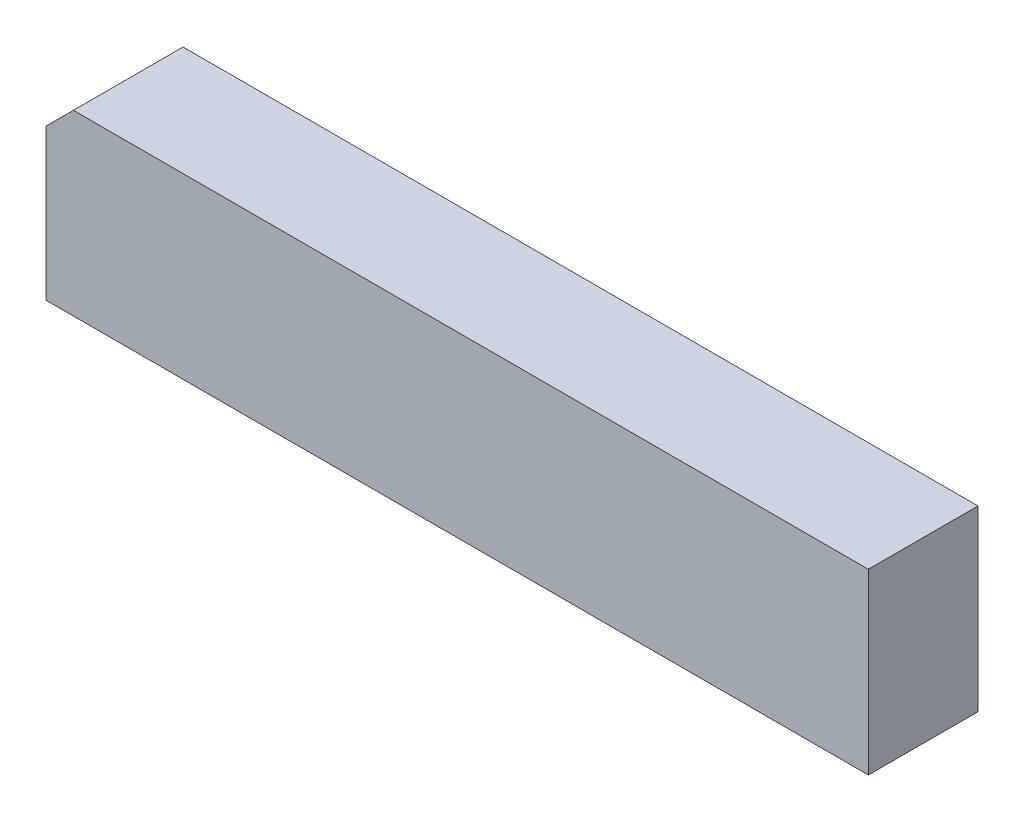
from build123d import *

# Parameters (mm, degrees)
AUFSATZ_LINEAR_AUSTRAGEN1_DEPTH = 4


with BuildPart() as part:
    # Skizze1 → Aufsatz-Linear austragen1 (new body)
    with BuildSketch(Plane.XY):
        Polygon((0, 5.5), (1, 6.5), (30, 6.5), (30, 0), (0, 0), align=None)
    extrude(amount=AUFSATZ_LINEAR_AUSTRAGEN1_DEPTH)


solid = part.part
